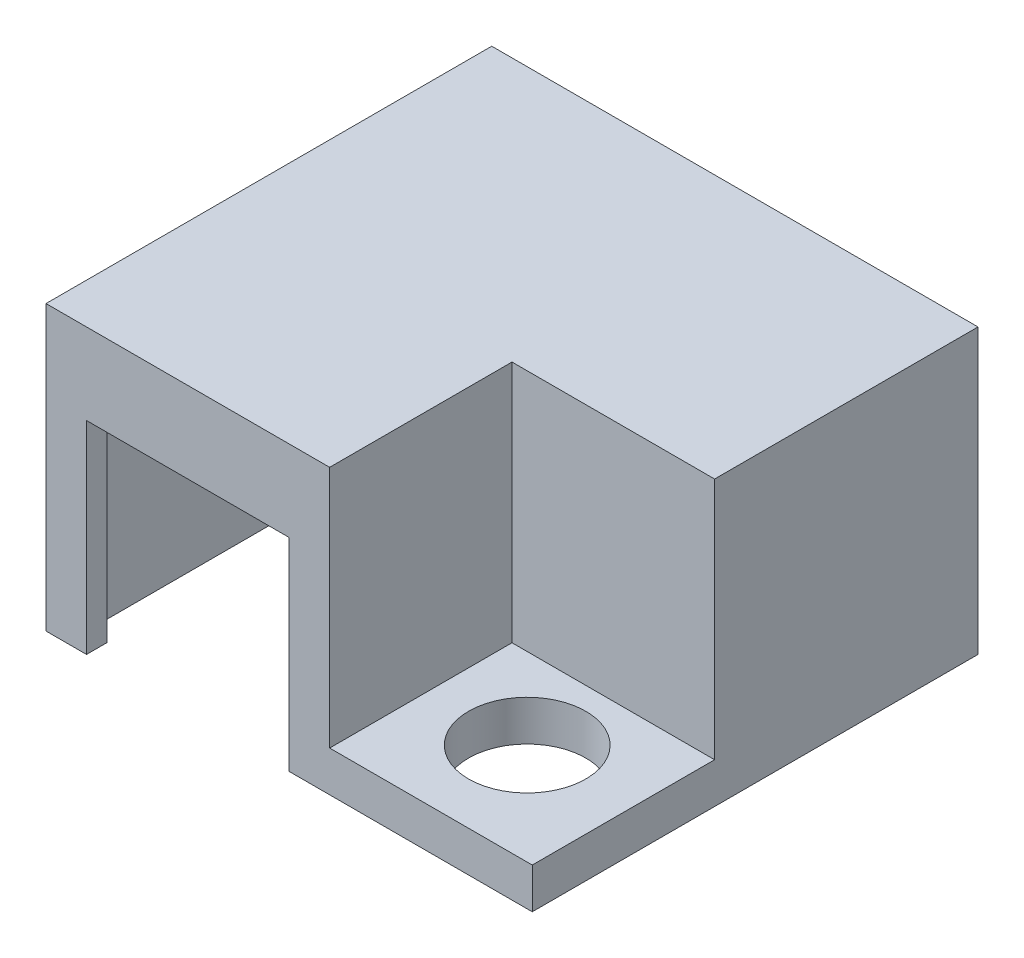
from build123d import *

# Parameters (mm, degrees)
ESQUISSE1_W             = 24
ESQUISSE1_H             = 22
BOSS_EXTRU_1_DEPTH      = 2
ENL_V_MAT_EXTRU_1_DEPTH = 2
ESQUISSE3_R             = 1.75
ENL_V_MAT_EXTRU_2_DEPTH = 2
ESQUISSE4_R             = 2.894655209
ENL_V_MAT_EXTRU_3_DEPTH = 2
BOSS_EXTRU_2_DEPTH      = 10
ESQUISSE6_W             = 10
ESQUISSE6_H             = 10
ENL_V_MAT_EXTRU_4_DEPTH = 10
BOSS_EXTRU_3_DEPTH      = 2


with BuildPart() as part:
    # Esquisse1 → Boss.-Extru.1 (new body)
    with BuildSketch(Plane(origin=(0, 0, 0), x_dir=(1, 0, 0), z_dir=(0, 1, 0))):
        with Locations((12, 11)):
            Rectangle(ESQUISSE1_W, ESQUISSE1_H)
    extrude(amount=BOSS_EXTRU_1_DEPTH)

    # Esquisse2 → Enlèv. mat.-Extru.1 (cut)
    with BuildSketch(Plane(origin=(0, 2, 0), x_dir=(1, 0, 0), z_dir=(0, 1, 0))):
        Polygon((1, 21), (23, 21), (23, 10), (13, 10), (13, 1), (1, 1), align=None)
    extrude(amount=-ENL_V_MAT_EXTRU_1_DEPTH, mode=Mode.SUBTRACT)

    # Esquisse3 → Enlèv. mat.-Extru.2 (cut)
    with BuildSketch(Plane(origin=(0, 2, 0), x_dir=(1, 0, 0), z_dir=(0, 1, 0))):
        with Locations((18.75, 5)):
            Circle(ESQUISSE3_R)
    extrude(amount=-ENL_V_MAT_EXTRU_2_DEPTH, mode=Mode.SUBTRACT)

    # Esquisse4 → Enlèv. mat.-Extru.3 (cut)
    with BuildSketch(Plane(origin=(0, 2, 0), x_dir=(1, 0, 0), z_dir=(0, 1, 0))):
        with Locations((18.75, 5)):
            Circle(ESQUISSE4_R)
    extrude(amount=-ENL_V_MAT_EXTRU_3_DEPTH, mode=Mode.SUBTRACT)

    # Esquisse5 → Boss.-Extru.2 (add)
    with BuildSketch(Plane(origin=(0, 2, 0), x_dir=(1, 0, 0), z_dir=(0, 1, 0))):
        Polygon((14, 0), (14, 9), (24, 9), (24, 22), (0, 22), (0, 0), align=None)
        Polygon((1, 1), (1, 21), (23, 21), (23, 10), (13, 10), (13, 1), align=None, mode=Mode.SUBTRACT)
    extrude(amount=BOSS_EXTRU_2_DEPTH)

    # Esquisse6 → Enlèv. mat.-Extru.4 (cut)
    with BuildSketch(Plane.XY):
        with Locations((7, 5)):
            Rectangle(ESQUISSE6_W, ESQUISSE6_H)
    extrude(amount=-ENL_V_MAT_EXTRU_4_DEPTH, mode=Mode.SUBTRACT)

    # Esquisse8 → Boss.-Extru.3 (add)
    with BuildSketch(Plane(origin=(0, 12, 0), x_dir=(1, 0, 0), z_dir=(0, 1, 0))):
        Polygon((0, 0), (0, 22), (24, 22), (24, 9), (14, 9), (14, 0), align=None)
    extrude(amount=BOSS_EXTRU_3_DEPTH)


solid = part.part
